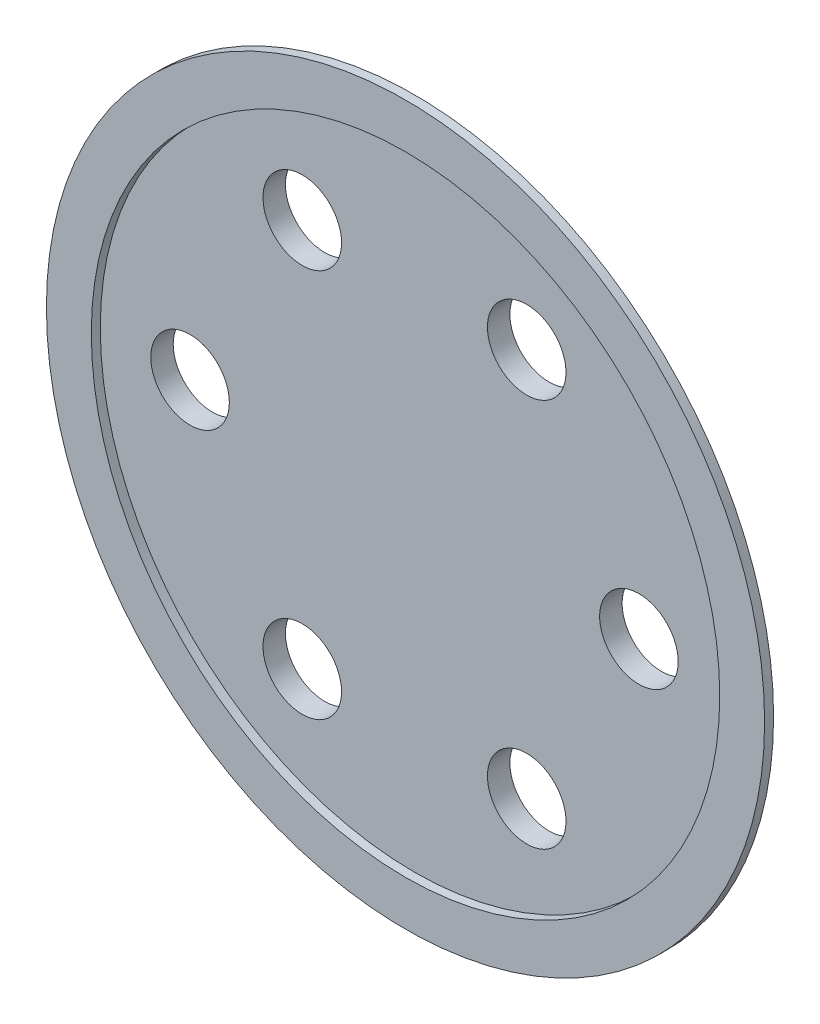
from build123d import *

# Parameters (mm, degrees)
SKETCH_1_R          = 16
SKETCH_1_R_2        = 14
EXTRUDE_1_DEPTH     = 0.4
SKETCH_2_R          = 14
EXTRUDE_1_2_DEPTH   = 1
SKETCH_3_R          = 1.75
CUT_EXTRUDE_1_DEPTH = 1
SCALE_1_SCALE       = 0.35


with BuildPart() as part:
    # 草图1 → Extrude 1 (new body)
    with BuildSketch(Plane.XY):
        Circle(SKETCH_1_R)
        Circle(SKETCH_1_R_2, mode=Mode.SUBTRACT)
    extrude(amount=EXTRUDE_1_DEPTH)


with BuildPart() as body_2:
    # 草图2 → Extrude 1 2 (new body)
    with BuildSketch(Plane(origin=(0, 0, 0), x_dir=(-1, 0, 0), z_dir=(0, 0, -1))):
        Circle(SKETCH_2_R)
    extrude(amount=EXTRUDE_1_2_DEPTH)

    # 草图3 → 切除-拉伸1 (cut)
    with BuildSketch(Plane.XY):
        with Locations((10, 0)):
            Circle(SKETCH_3_R)
        with Locations((5, -8.660254038)):
            Circle(SKETCH_3_R)
        with Locations((-5, -8.660254038)):
            Circle(SKETCH_3_R)
        with Locations((-10, 0)):
            Circle(SKETCH_3_R)
        with Locations((-5, 8.660254038)):
            Circle(SKETCH_3_R)
        with Locations((5, 8.660254038)):
            Circle(SKETCH_3_R)
    extrude(amount=-CUT_EXTRUDE_1_DEPTH, mode=Mode.SUBTRACT)


with BuildPart() as part_1:
    # 缩放比例1: scaled about (0, 0, 0)
    add(part.part.scale(SCALE_1_SCALE))


with BuildPart() as body_2_1:
    # 缩放比例1: scaled about (0, 0, 0)
    add(body_2.part.scale(SCALE_1_SCALE))


solid = Compound([part_1.part, body_2_1.part])
